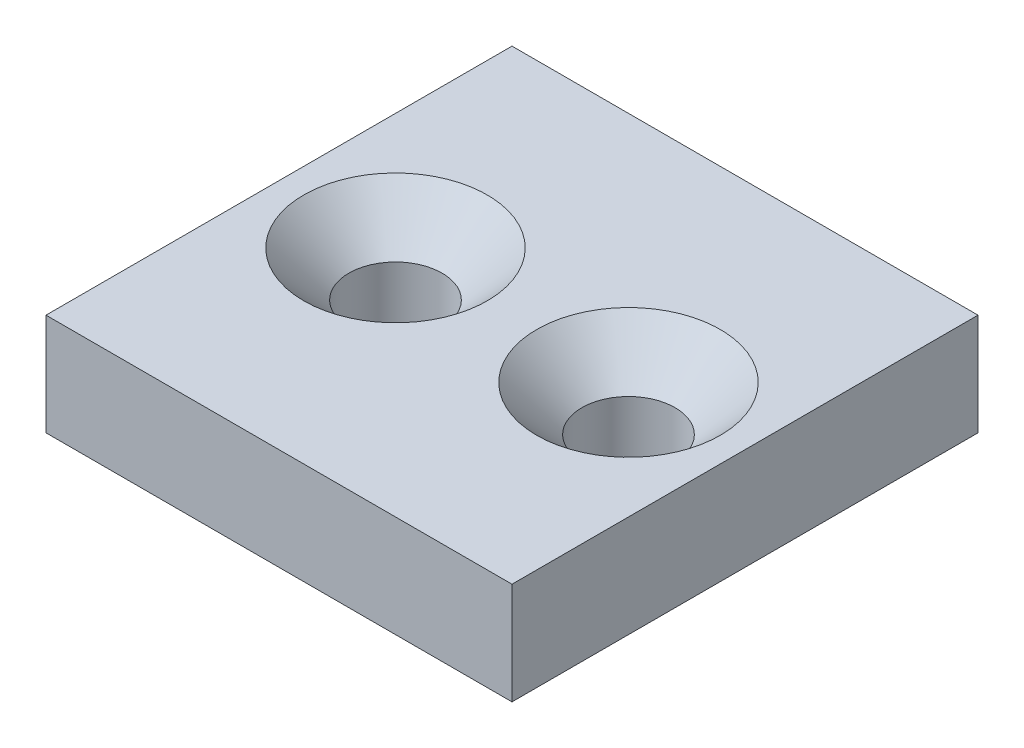
from build123d import *

# Parameters (mm, degrees)
SKETCH1_W           = 32
SKETCH1_H           = 32
BOSS_EXTRUDE1_DEPTH = 7
HOLE1_D             = 6.4
HOLE1_DEPTH         = 7
HOLE1_CSINK_D       = 12.6
HOLE1_CSINK_ANGLE   = 90


with BuildPart() as part:
    # Sketch1 → Boss-Extrude1 (new body)
    with BuildSketch(Plane(origin=(0, 0, 0), x_dir=(1, 0, 0), z_dir=(0, 1, 0))):
        Rectangle(SKETCH1_W, SKETCH1_H)
    extrude(amount=BOSS_EXTRUDE1_DEPTH)

    # Hole1
    with Locations(Plane(origin=(0, 7, 0), x_dir=(1, 0, 0), z_dir=(0, 1, 0))):
        with Locations((8, 0), (-8, 0)):
            CounterSinkHole(HOLE1_D / 2, HOLE1_CSINK_D / 2, depth=HOLE1_DEPTH, counter_sink_angle=HOLE1_CSINK_ANGLE)


solid = part.part
